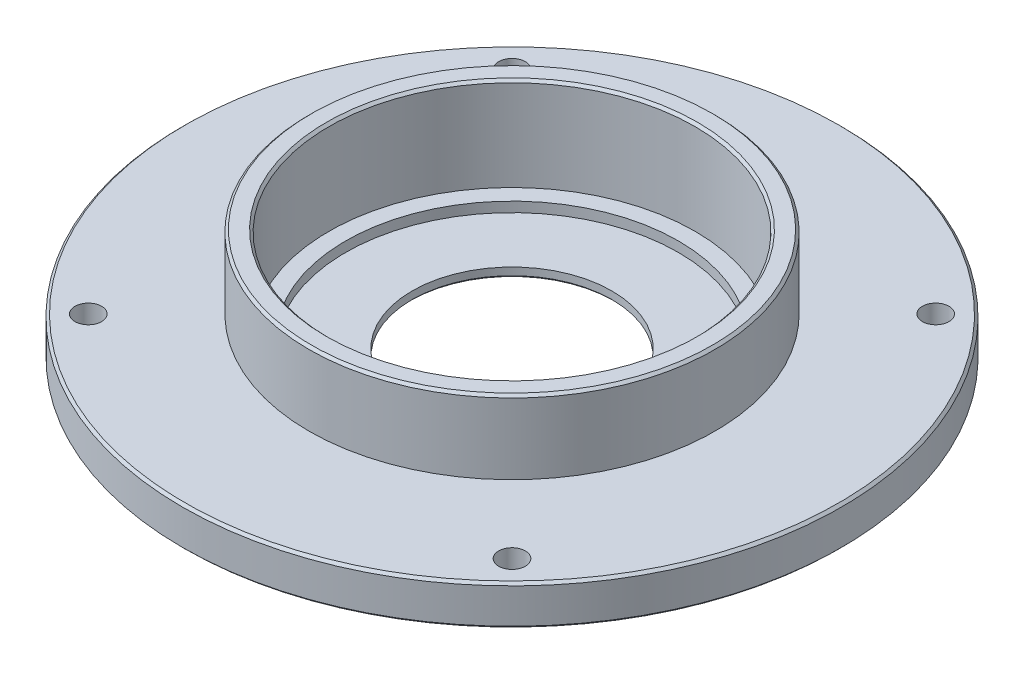
from build123d import *

# Parameters (mm, degrees)
CUT_EXTRUDE1_REACH = 14
SKETCH2_R          = 4
CHAMFER1_SIZE      = 0.75


with BuildPart() as part:
    # Sketch1 → Revolve2 (revolve)
    with BuildSketch(Plane.XY):
        Polygon((-50, 3), (-50, 6), (-55, 6), (-55, 34), (-61, 34), (-61, 12), (-99, 12), (-99, 0), (-30, 0), (-30, 3), align=None)
    revolve(axis=Axis((0, 0, 0), (0, 1, 0)))

    # Sketch2 → Cut-Extrude1 (cut, up to next)
    with BuildSketch(Plane(origin=(0, 12, 0), x_dir=(1, 0, 0), z_dir=(0, 1, 0)), mode=Mode.PRIVATE) as cut_extrude1_sk1:
        with Locations((-63.639610307, 63.639610307)):
            Circle(SKETCH2_R)
    cut_extrude1_tool1 = extrude(cut_extrude1_sk1.sketch, amount=-CUT_EXTRUDE1_REACH, mode=Mode.PRIVATE) & part.part
    add(cut_extrude1_tool1.solids().sort_by_distance((-63.63961, 12, -63.63961))[0], mode=Mode.SUBTRACT)
    # Sketch2 → Cut-Extrude1 (cut, up to next)
    with BuildSketch(Plane(origin=(0, 12, 0), x_dir=(1, 0, 0), z_dir=(0, 1, 0)), mode=Mode.PRIVATE) as cut_extrude1_sk2:
        with Locations((63.639610307, 63.639610307)):
            Circle(SKETCH2_R)
    cut_extrude1_tool2 = extrude(cut_extrude1_sk2.sketch, amount=-CUT_EXTRUDE1_REACH, mode=Mode.PRIVATE) & part.part
    add(cut_extrude1_tool2.solids().sort_by_distance((63.63961, 12, -63.63961))[0], mode=Mode.SUBTRACT)
    # Sketch2 → Cut-Extrude1 (cut, up to next)
    with BuildSketch(Plane(origin=(0, 12, 0), x_dir=(1, 0, 0), z_dir=(0, 1, 0)), mode=Mode.PRIVATE) as cut_extrude1_sk3:
        with Locations((63.639610307, -63.639610307)):
            Circle(SKETCH2_R)
    cut_extrude1_tool3 = extrude(cut_extrude1_sk3.sketch, amount=-CUT_EXTRUDE1_REACH, mode=Mode.PRIVATE) & part.part
    add(cut_extrude1_tool3.solids().sort_by_distance((63.63961, 12, 63.63961))[0], mode=Mode.SUBTRACT)
    # Sketch2 → Cut-Extrude1 (cut, up to next)
    with BuildSketch(Plane(origin=(0, 12, 0), x_dir=(1, 0, 0), z_dir=(0, 1, 0)), mode=Mode.PRIVATE) as cut_extrude1_sk4:
        with Locations((-63.639610307, -63.639610307)):
            Circle(SKETCH2_R)
    cut_extrude1_tool4 = extrude(cut_extrude1_sk4.sketch, amount=-CUT_EXTRUDE1_REACH, mode=Mode.PRIVATE) & part.part
    add(cut_extrude1_tool4.solids().sort_by_distance((-63.63961, 12, 63.63961))[0], mode=Mode.SUBTRACT)

    # Chamfer1
    chamfer1_edges = [part.edges().sort_by_distance(p)[0] for p in [
        (55, 34, 0),
        (61, 34, 0),
        (99, 12, 0),
        (99, 0, 0),
        (30, 0, 0),
    ]]
    chamfer(chamfer1_edges, length=CHAMFER1_SIZE)


solid = part.part
